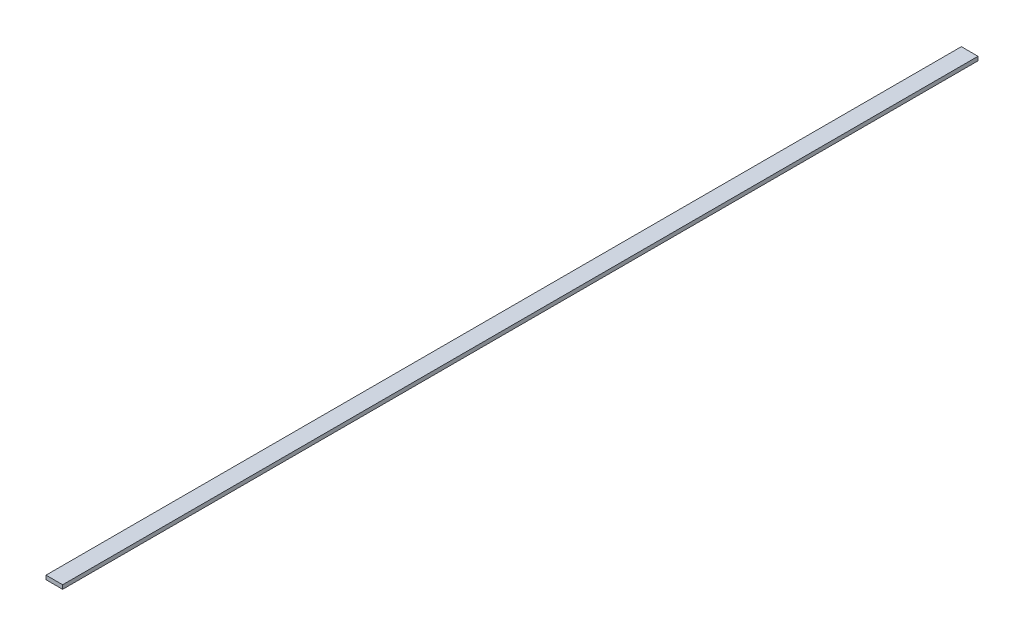
from build123d import *

# Parameters (mm, degrees)
SKETCH1_W           = 6.35
SKETCH1_H           = 1.51892
BOSS_EXTRUDE1_DEPTH = 349.25


with BuildPart() as part:
    # Sketch1 → Boss-Extrude1 (new body)
    with BuildSketch(Plane.XY):
        with Locations((3.175, 0.75946)):
            Rectangle(SKETCH1_W, SKETCH1_H)
    extrude(amount=BOSS_EXTRUDE1_DEPTH)


solid = part.part
